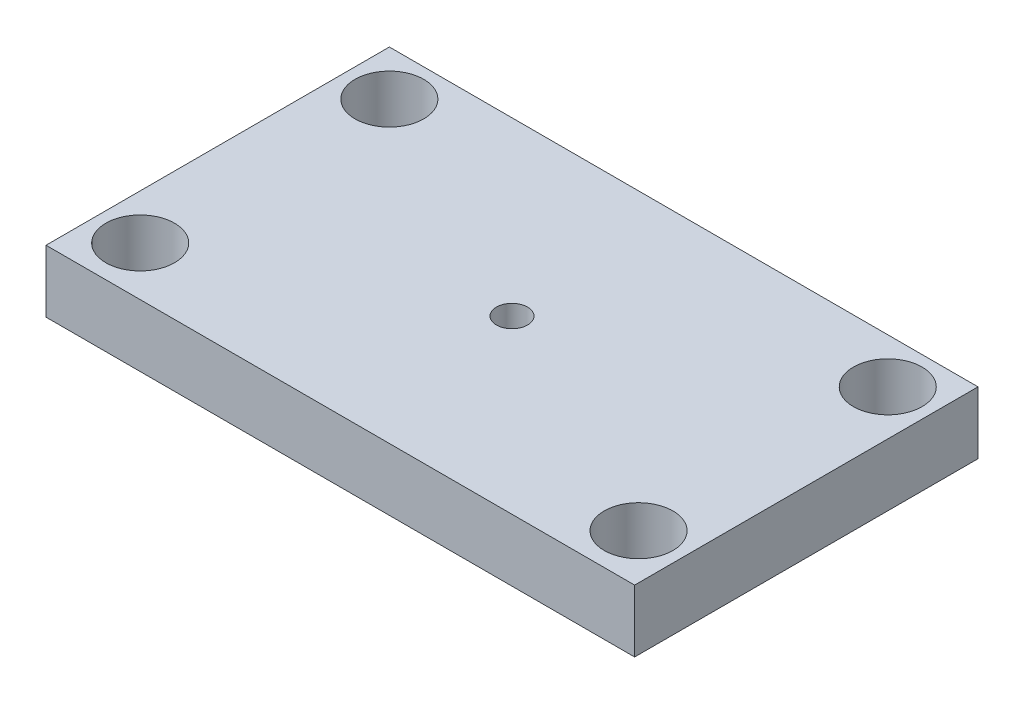
from build123d import *

# Parameters (mm, degrees)
SKETCH1_W           = 60
SKETCH1_H           = 35
SKETCH1_R           = 3.5
SKETCH1_R_2         = 1.5875
BOSS_EXTRUDE1_DEPTH = 6.35


with BuildPart() as part:
    # Sketch1 → Boss-Extrude1 (new body)
    with BuildSketch(Plane(origin=(0, 0, 0), x_dir=(1, 0, 0), z_dir=(0, 1, 0))):
        with Locations((30, 17.5)):
            Rectangle(SKETCH1_W, SKETCH1_H)
        with Locations((4.6, 30.4)):
            Circle(SKETCH1_R, mode=Mode.SUBTRACT)
        with Locations((55.4, 30.4)):
            Circle(SKETCH1_R, mode=Mode.SUBTRACT)
        with Locations((4.6, 5)):
            Circle(SKETCH1_R, mode=Mode.SUBTRACT)
        with Locations((55.4, 5)):
            Circle(SKETCH1_R, mode=Mode.SUBTRACT)
        with Locations((30, 17.5)):
            Circle(SKETCH1_R_2, mode=Mode.SUBTRACT)
    extrude(amount=BOSS_EXTRUDE1_DEPTH)


solid = part.part
